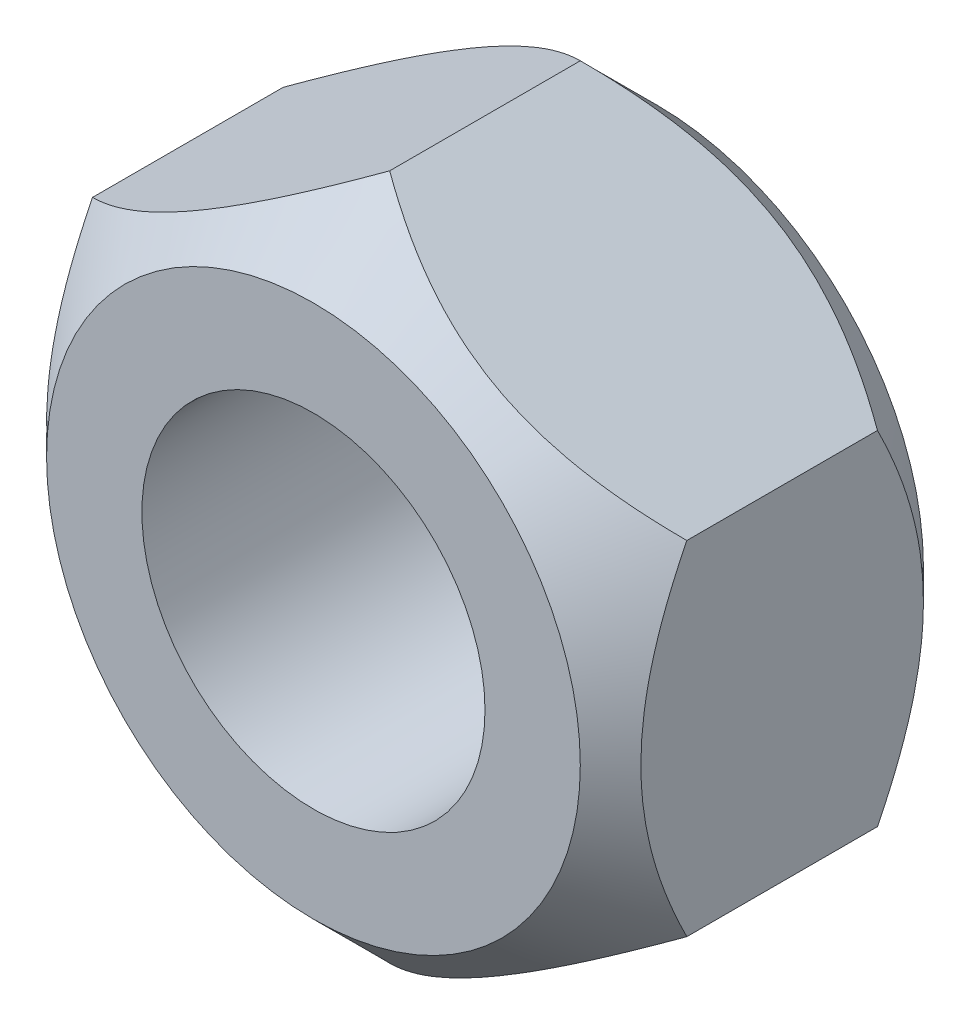
from build123d import *

# Parameters (mm, degrees)
SKETCH1_R           = 4.5
BOSS_EXTRUDE1_DEPTH = 4.5
SKETCH2_OUTSIDE_W   = 40.68
SKETCH2_OUTSIDE_H   = 43.092
SKETCH2_OUTSIDE_R   = 7
CUT_EXTRUDE1_DEPTH  = 9
CUT_EXTRUDE1_TAPER  = 45


with BuildPart() as part:
    # Sketch1 → Boss-Extrude1 (new body, symmetric)
    with BuildSketch(Plane.XY):
        Polygon((7.794228634, -4.5), (7.794228634, 4.5), (0, 9), (-7.794228634, 4.5), (-7.794228634, -4.5), (0, -9), align=None)
        Circle(SKETCH1_R, mode=Mode.SUBTRACT)
    extrude(amount=BOSS_EXTRUDE1_DEPTH, both=True)

    # Sketch2 outside → Cut-Extrude1 (cut)
    with BuildSketch(Plane.XY.offset(4.5)):
        Rectangle(SKETCH2_OUTSIDE_W, SKETCH2_OUTSIDE_H)
        Circle(SKETCH2_OUTSIDE_R, mode=Mode.SUBTRACT)
    cut_extrude1 = extrude(amount=-CUT_EXTRUDE1_DEPTH, taper=CUT_EXTRUDE1_TAPER, mode=Mode.SUBTRACT)

    # Mirror1: Cut-Extrude1 across plane
    add(cut_extrude1.mirror(Plane.XY), mode=Mode.SUBTRACT)


solid = part.part
